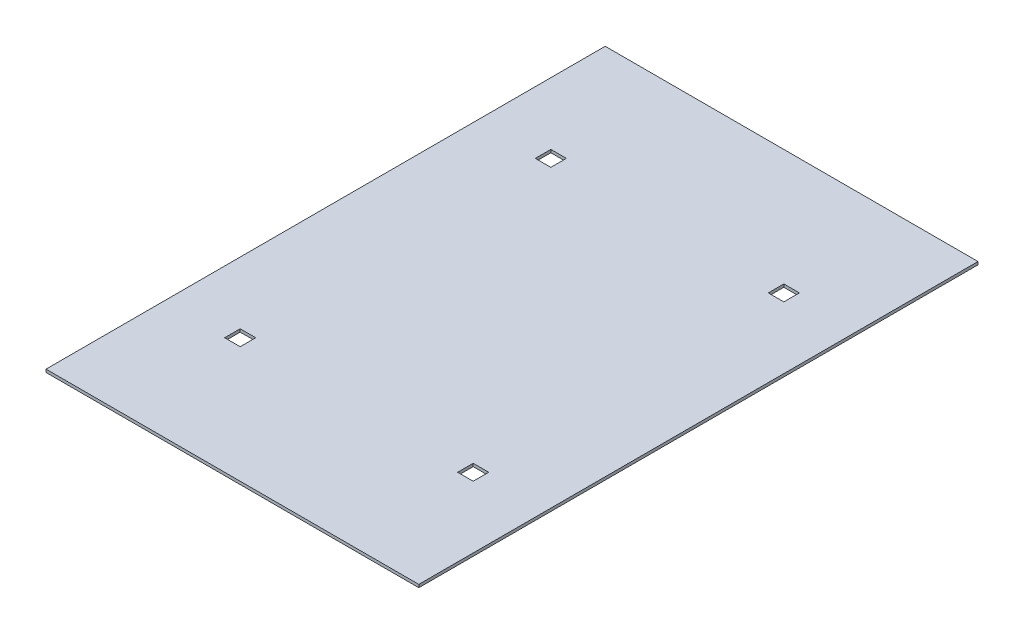
from build123d import *

# Parameters (mm, degrees)
SKETCH1_W           = 609.6
SKETCH1_H           = 914.4
BOSS_EXTRUDE1_DEPTH = 4.7625
SKETCH2_W           = 25.4
SKETCH2_H           = 25.4
CUT_EXTRUDE1_DEPTH  = 5.7625


with BuildPart() as part:
    # Sketch1 → Boss-Extrude1 (new body)
    with BuildSketch(Plane(origin=(0, 0, 0), x_dir=(1, 0, 0), z_dir=(0, 1, 0))):
        with Locations((304.8, 457.2)):
            Rectangle(SKETCH1_W, SKETCH1_H)
    extrude(amount=BOSS_EXTRUDE1_DEPTH)

    # Sketch2 → Cut-Extrude1 (cut, through all)
    with BuildSketch(Plane(origin=(0, 4.7625, 0), x_dir=(1, 0, 0), z_dir=(0, 1, 0))):
        with Locations((114.3, 711.2)):
            Rectangle(SKETCH2_W, SKETCH2_H)
        with Locations((495.3, 711.2)):
            Rectangle(SKETCH2_W, SKETCH2_H)
        with Locations((114.3, 203.2)):
            Rectangle(SKETCH2_W, SKETCH2_H)
        with Locations((495.3, 203.2)):
            Rectangle(SKETCH2_W, SKETCH2_H)
    extrude(amount=-CUT_EXTRUDE1_DEPTH, mode=Mode.SUBTRACT)


solid = part.part
